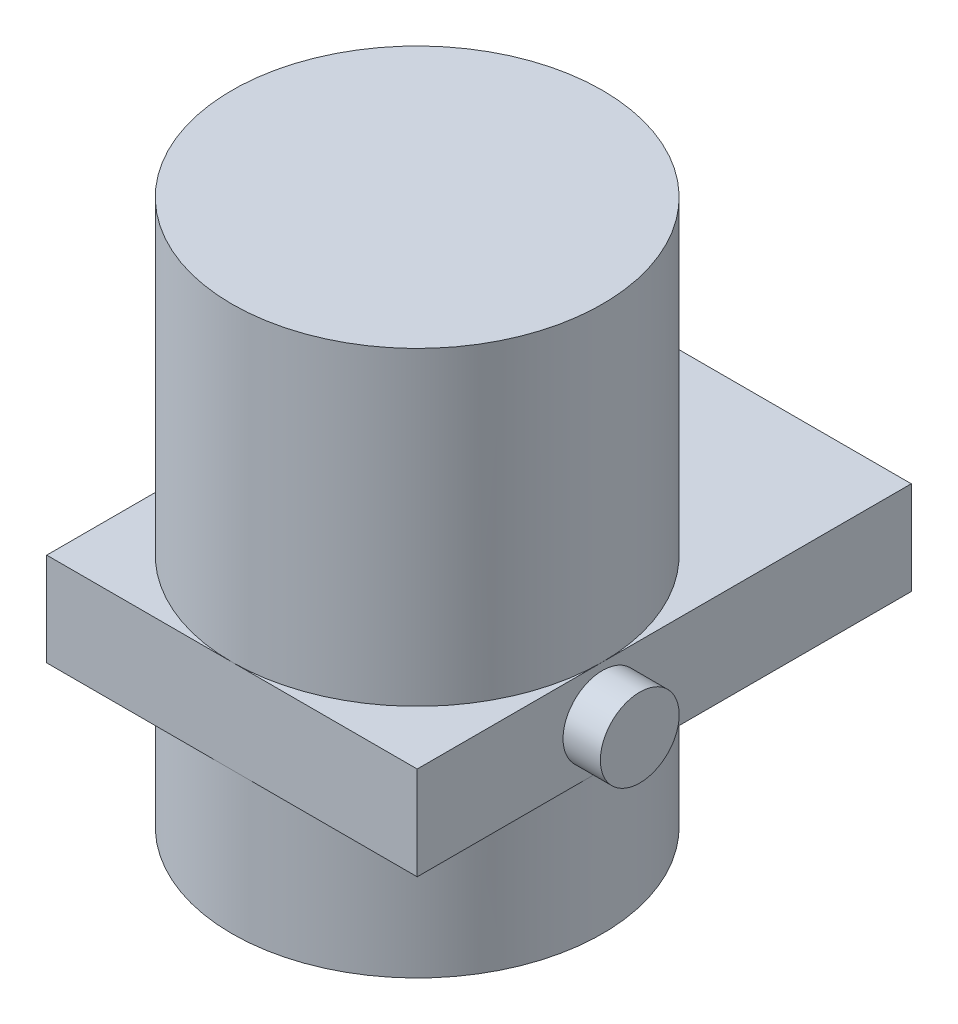
from build123d import *

# Parameters (mm, degrees)
SKETCH1_W                = 251.968
SKETCH1_H                = 336.042
BOSS_EXTRUDE1_DEPTH      = 63.5
SKETCH2_R                = 125.984
BOSS_EXTRUDE2_DEPTH      = 96.52
BOSS_EXTRUDE2_DEPTH_BACK = 274.32
SKETCH4_R                = 26.797
BOSS_EXTRUDE7_DEPTH      = 25.4


with BuildPart() as part:
    # Sketch1 → Boss-Extrude1 (new body)
    with BuildSketch(Plane(origin=(0, 0, 0), x_dir=(1, 0, 0), z_dir=(0, 1, 0))):
        with Locations((0, 42.037)):
            Rectangle(SKETCH1_W, SKETCH1_H)
    extrude(amount=BOSS_EXTRUDE1_DEPTH)

    # Sketch2 → Boss-Extrude2 (add, two sides)
    with BuildSketch(Plane.XZ) as boss_extrude2_sk:
        Circle(SKETCH2_R)
    extrude(amount=BOSS_EXTRUDE2_DEPTH)
    extrude(boss_extrude2_sk.sketch, amount=-BOSS_EXTRUDE2_DEPTH_BACK)

    # Sketch4 → Boss-Extrude7 (add)
    with BuildSketch(Plane(origin=(125.984, 0, 0), x_dir=(0, 0, -1), z_dir=(1, 0, 0))):
        with Locations((0, 31.75)):
            Circle(SKETCH4_R)
    extrude(amount=BOSS_EXTRUDE7_DEPTH)


solid = part.part
